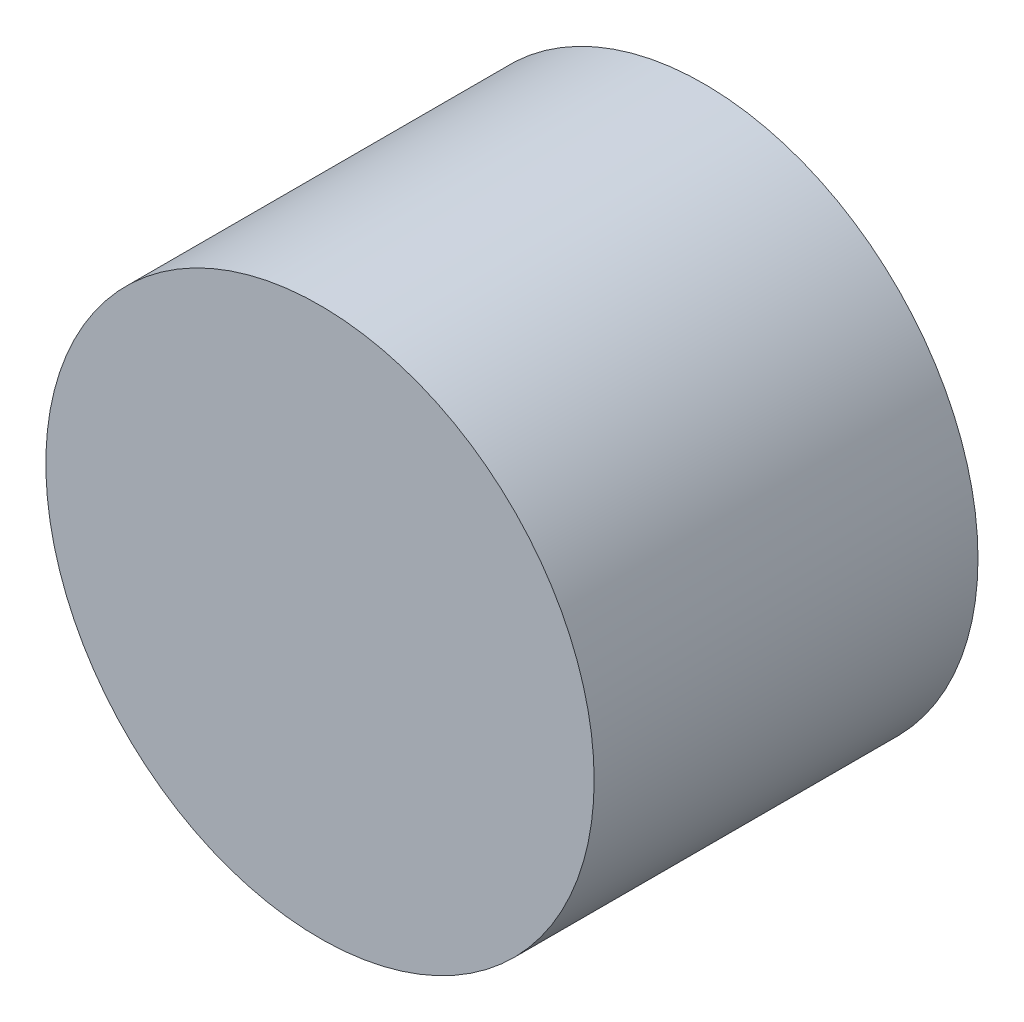
from build123d import *

# Parameters (mm, degrees)
SKETCH1_R           = 2.5
BOSS_EXTRUDE1_DEPTH = 3.5


with BuildPart() as part:
    # Sketch1 → Boss-Extrude1 (new body)
    with BuildSketch(Plane.XY):
        Circle(SKETCH1_R)
    extrude(amount=BOSS_EXTRUDE1_DEPTH)


solid = part.part
